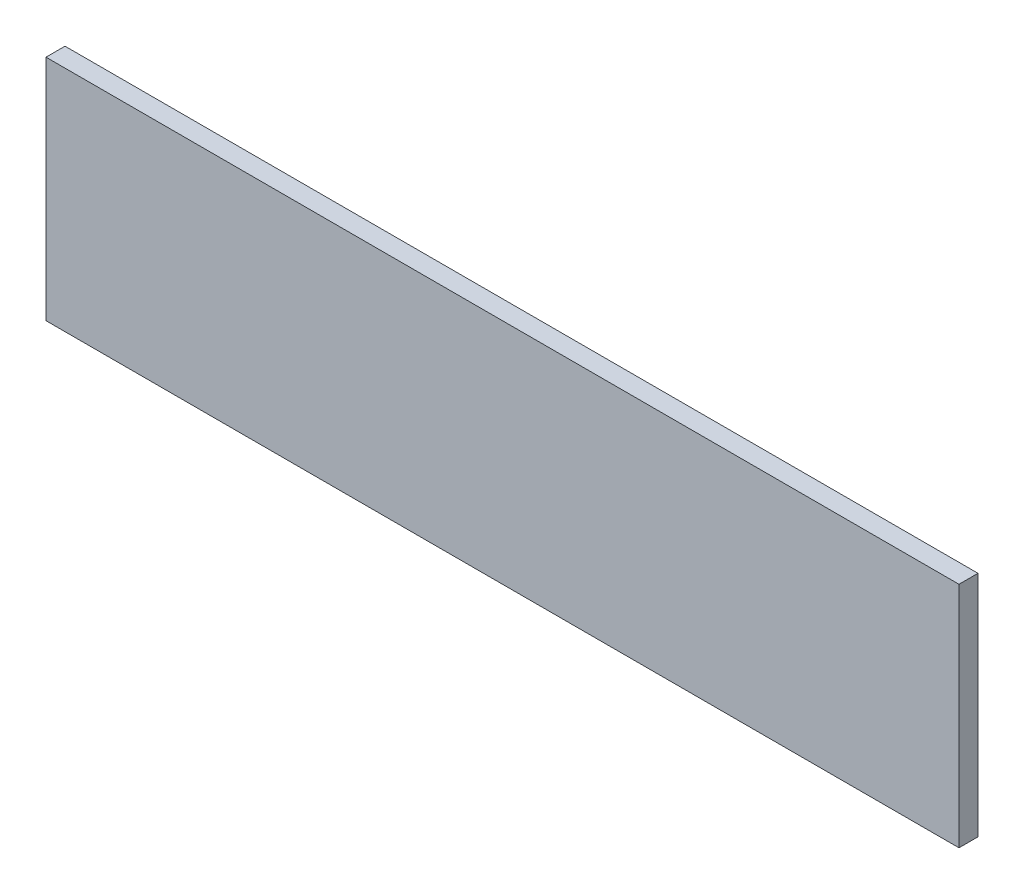
from build123d import *

# Parameters (mm, degrees)
SKETCH1_W           = 304.8
SKETCH1_H           = 76.2
BOSS_EXTRUDE1_DEPTH = 6.35


with BuildPart() as part:
    # Sketch1 → Boss-Extrude1 (new body)
    with BuildSketch(Plane.XY):
        with Locations((152.4, 38.1)):
            Rectangle(SKETCH1_W, SKETCH1_H)
    extrude(amount=BOSS_EXTRUDE1_DEPTH)


solid = part.part
